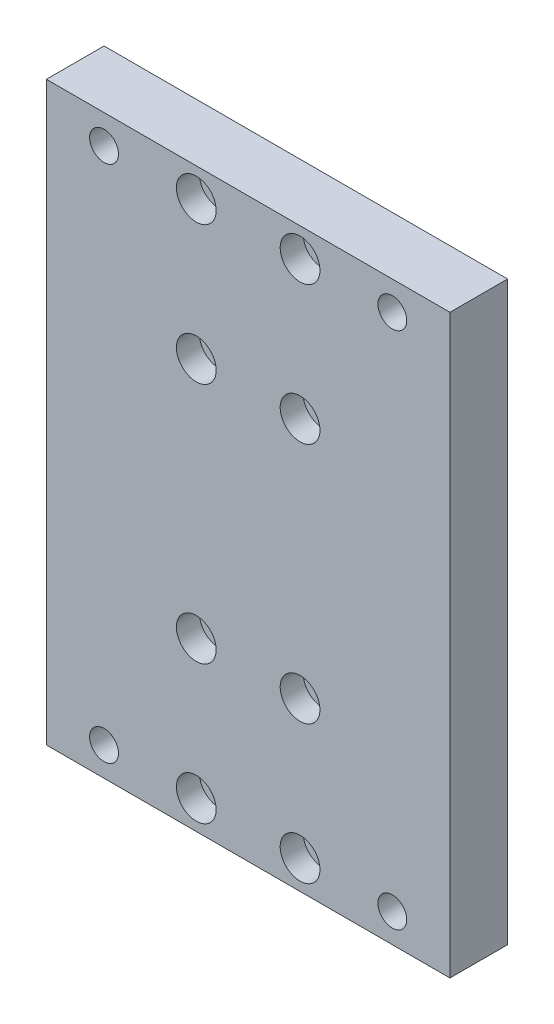
from build123d import *

# Parameters (mm, degrees)
SKETCH1_W           = 70
SKETCH1_H           = 100
BOSS_EXTRUDE1_DEPTH = 10
SKETCH2_R           = 2.5
CUT_EXTRUDE1_DEPTH  = 11
SKETCH3_R           = 1.5
CUT_EXTRUDE2_DEPTH  = 11
SKETCH4_R           = 3.45
CUT_EXTRUDE3_DEPTH  = 4


with BuildPart() as part:
    # Sketch1 → Boss-Extrude1 (new body)
    with BuildSketch(Plane.XY):
        Rectangle(SKETCH1_W, SKETCH1_H)
    extrude(amount=BOSS_EXTRUDE1_DEPTH)

    # Sketch2 → Cut-Extrude1 (cut, through all)
    with BuildSketch(Plane(origin=(0, 0, 0), x_dir=(-1, 0, 0), z_dir=(0, 0, -1))):
        with Locations((-25, 45)):
            Circle(SKETCH2_R)
        with Locations((25, 45)):
            Circle(SKETCH2_R)
        with Locations((-25, -45)):
            Circle(SKETCH2_R)
        with Locations((25, -45)):
            Circle(SKETCH2_R)
    extrude(amount=-CUT_EXTRUDE1_DEPTH, mode=Mode.SUBTRACT)

    # Sketch3 → Cut-Extrude2 (cut, through all)
    with BuildSketch(Plane(origin=(0, 0, 0), x_dir=(-1, 0, 0), z_dir=(0, 0, -1))):
        with Locations((9, 21)):
            Circle(SKETCH3_R)
        with Locations((9, 45)):
            Circle(SKETCH3_R)
        with Locations((-9, 21)):
            Circle(SKETCH3_R)
        with Locations((-9, 45)):
            Circle(SKETCH3_R)
        with Locations((9, -45)):
            Circle(SKETCH3_R)
        with Locations((9, -21)):
            Circle(SKETCH3_R)
        with Locations((-9, -45)):
            Circle(SKETCH3_R)
        with Locations((-9, -21)):
            Circle(SKETCH3_R)
    extrude(amount=-CUT_EXTRUDE2_DEPTH, mode=Mode.SUBTRACT)

    # Sketch4 → Cut-Extrude3 (cut)
    with BuildSketch(Plane.XY.offset(10)):
        with Locations((-9, 45)):
            Circle(SKETCH4_R)
        with Locations((-9, 21)):
            Circle(SKETCH4_R)
        with Locations((9, 21)):
            Circle(SKETCH4_R)
        with Locations((9, 45)):
            Circle(SKETCH4_R)
        with Locations((9, -21)):
            Circle(SKETCH4_R)
        with Locations((-9, -21)):
            Circle(SKETCH4_R)
        with Locations((-9, -45)):
            Circle(SKETCH4_R)
        with Locations((9, -45)):
            Circle(SKETCH4_R)
    extrude(amount=-CUT_EXTRUDE3_DEPTH, mode=Mode.SUBTRACT)


solid = part.part
